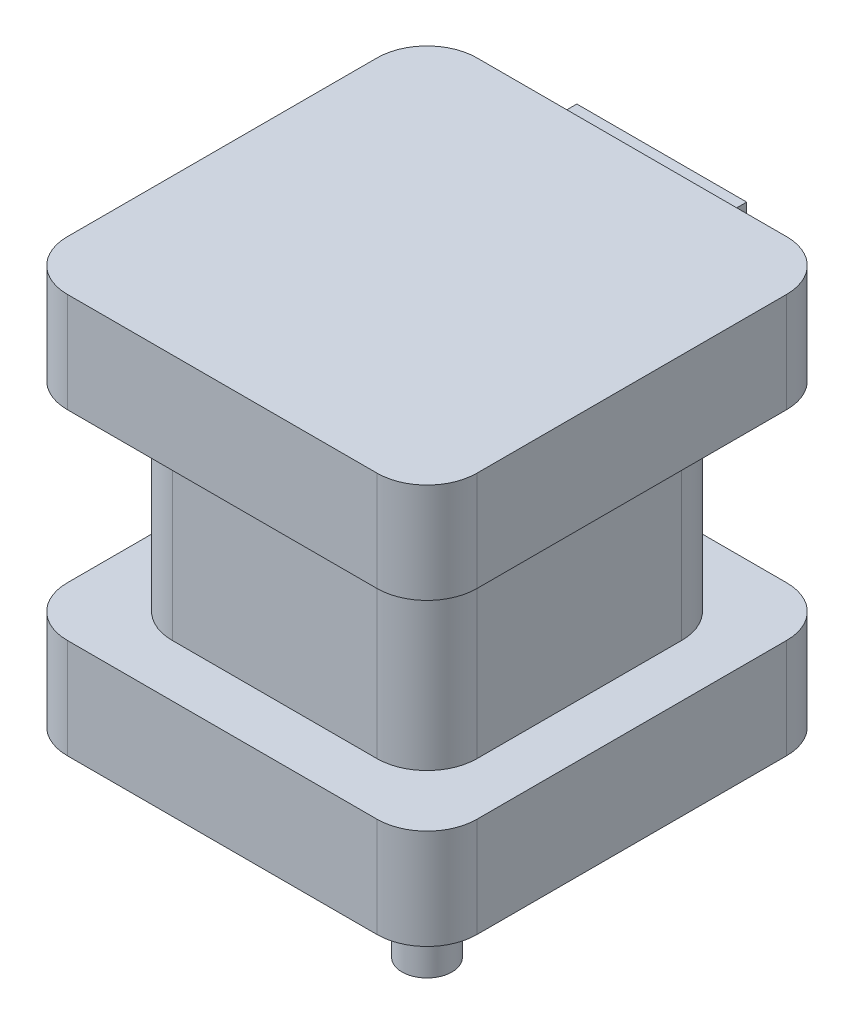
from build123d import *

# Parameters (mm, degrees)
SKETCH1_R           = 2.5
BOSS_EXTRUDE1_DEPTH = 20
BOSS_EXTRUDE2_START = 20
SKETCH1_3_W         = 41
SKETCH1_3_H         = 41
SKETCH1_3_R         = 2.5
BOSS_EXTRUDE2_DEPTH = 10
BOSS_EXTRUDE3_START = 20
SKETCH1_4_W         = 30.5
SKETCH1_4_H         = 30.5
SKETCH1_4_R         = 2.5
BOSS_EXTRUDE3_DEPTH = 30
BOSS_EXTRUDE4_START = 50
SKETCH1_5_W         = 41
SKETCH1_5_H         = 41
BOSS_EXTRUDE4_DEPTH = 10
FILLET1_R           = 5
SKETCH2_R           = 1.75
CUT_EXTRUDE1_DEPTH  = 8
SKETCH3_R           = 13
BOSS_EXTRUDE5_DEPTH = 4
CHAMFER1_SIZE       = 1
SKETCH4_W           = 17
SKETCH4_H           = 6
SKETCH4_W_2         = 15
SKETCH4_H_2         = 4
EXTRUDE_THIN1_DEPTH = 3


with BuildPart() as part:
    # Sketch1 → Boss-Extrude1 (new body)
    with BuildSketch(Plane(origin=(0, 0, 0), x_dir=(1, 0, 0), z_dir=(0, 1, 0))):
        Circle(SKETCH1_R)
    extrude(amount=BOSS_EXTRUDE1_DEPTH)



with BuildPart() as body_2:
    # Sketch1_3 → Boss-Extrude2 (new body)
    with BuildSketch(Plane(origin=(0, 0, 0), x_dir=(1, 0, 0), z_dir=(0, 1, 0)).offset(BOSS_EXTRUDE2_START)):
        Rectangle(SKETCH1_3_W, SKETCH1_3_H)
        Circle(SKETCH1_3_R, mode=Mode.SUBTRACT)
    extrude(amount=BOSS_EXTRUDE2_DEPTH)

    # Sketch1_4 → Boss-Extrude3 (add)
    with BuildSketch(Plane(origin=(0, 0, 0), x_dir=(1, 0, 0), z_dir=(0, 1, 0)).offset(BOSS_EXTRUDE3_START)):
        Rectangle(SKETCH1_4_W, SKETCH1_4_H)
        Circle(SKETCH1_4_R, mode=Mode.SUBTRACT)
    extrude(amount=BOSS_EXTRUDE3_DEPTH)

    # Sketch1_5 → Boss-Extrude4 (add)
    with BuildSketch(Plane(origin=(0, 0, 0), x_dir=(1, 0, 0), z_dir=(0, 1, 0)).offset(BOSS_EXTRUDE4_START)):
        Rectangle(SKETCH1_5_W, SKETCH1_5_H)
    extrude(amount=BOSS_EXTRUDE4_DEPTH)

    # Fillet1
    fillet1_edges = [body_2.edges().sort_by_distance(p)[0] for p in [
        (-20.5, 25, -20.5),
        (20.5, 25, -20.5),
        (20.5, 25, 20.5),
        (-20.5, 25, 20.5),
        (15.25, 40, -15.25),
        (15.25, 40, 15.25),
        (-15.25, 40, 15.25),
        (-15.25, 40, -15.25),
        (-20.5, 55, -20.5),
        (-20.5, 55, 20.5),
        (20.5, 55, 20.5),
        (20.5, 55, -20.5),
    ]]
    fillet(fillet1_edges, radius=FILLET1_R)

    # Sketch2 → Cut-Extrude1 (cut)
    with BuildSketch(Plane.XZ.offset(-20)):
        with Locations((15.25, -15.25)):
            Circle(SKETCH2_R)
        with Locations((-15.25, -15.25)):
            Circle(SKETCH2_R)
    cut_extrude1 = extrude(amount=-CUT_EXTRUDE1_DEPTH, mode=Mode.SUBTRACT)

    # Mirror1: Cut-Extrude1 across plane
    add(cut_extrude1.mirror(Plane.XY), mode=Mode.SUBTRACT)


with BuildPart() as part_1:
    add(part.part)

    add(body_2.part)  # Boss-Extrude5 merges body 2
    # Sketch3 → Boss-Extrude5 (add)
    with BuildSketch(Plane.XZ.offset(-20)):
        Circle(SKETCH3_R)
    extrude(amount=BOSS_EXTRUDE5_DEPTH)

    # Chamfer1
    chamfer1_edges = [part_1.edges().sort_by_distance(p)[0] for p in [
        (-13, 16, 0),
    ]]
    chamfer(chamfer1_edges, length=CHAMFER1_SIZE)

    # Sketch4 → Extrude-Thin1 (add)
    with BuildSketch(Plane.XY.offset(-20.5)):
        with Locations((0, 55)):
            Rectangle(SKETCH4_W, SKETCH4_H)
        with Locations((0, 55)):
            Rectangle(SKETCH4_W_2, SKETCH4_H_2, mode=Mode.SUBTRACT)
    extrude(amount=-EXTRUDE_THIN1_DEPTH)


solid = part_1.part
